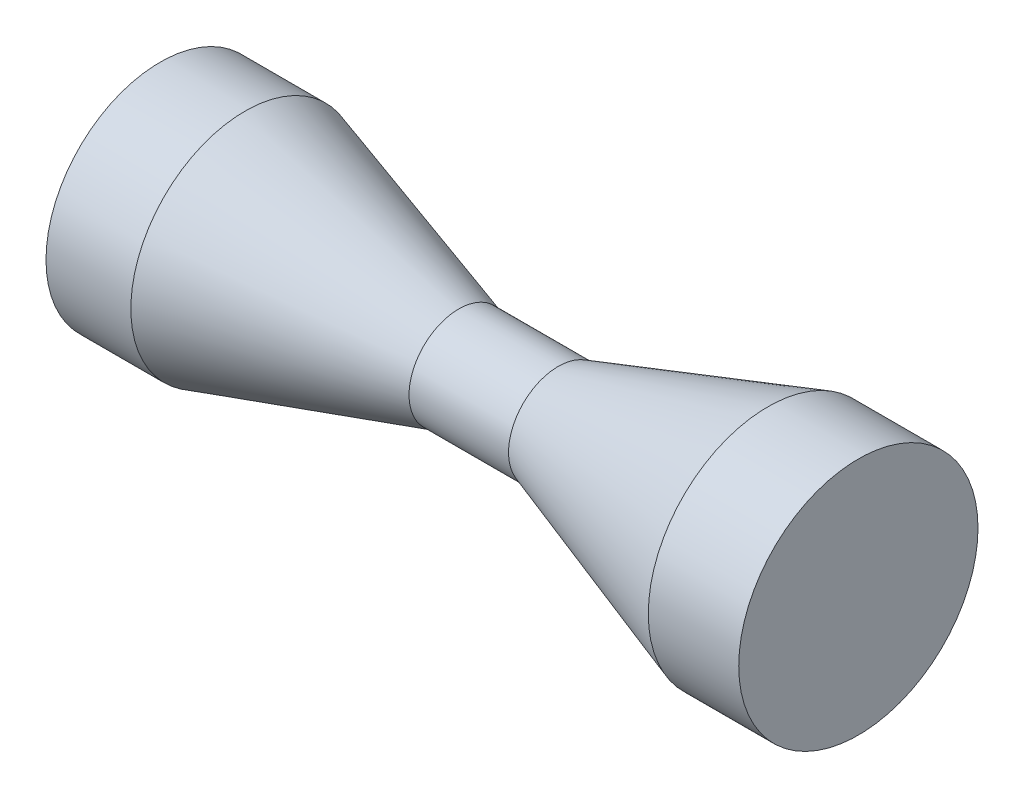
from build123d import *

# Parameters (mm, degrees)
SKETCH2_R           = 17.604244625
BOSS_EXTRUDE1_DEPTH = 2
SKETCH3_R           = 18.437955777
BOSS_EXTRUDE2_DEPTH = 2


with BuildPart() as part:
    # Sketch1 → Revolve-Thin2 (revolve)
    with BuildSketch(Plane.XY):
        Polygon((-49.689400151, 17.604244625), (-38.615762403, 17.604244625), (-5.678788589, 7.666364595), (9.653940601, 7.666364595), (41.968714147, 18.437955777), (53.905013296, 18.437955777), (53.905013296, 16.437955777), (42.293269467, 16.437955777), (9.978495921, 5.666364595), (-5.973941532, 5.666364595), (-38.910915347, 15.604244625), (-49.689400151, 15.604244625), align=None)
    revolve(axis=Axis((0, 0, 0), (-1, 0, 0)))

    # Sketch2 → Boss-Extrude1 (add)
    with BuildSketch(Plane.ZY.offset(49.689400151)):
        Circle(SKETCH2_R)
    extrude(amount=BOSS_EXTRUDE1_DEPTH)

    # Sketch3 → Boss-Extrude2 (add)
    with BuildSketch(Plane(origin=(53.905013296, 0, 0), x_dir=(0, 0, -1), z_dir=(1, 0, 0))):
        Circle(SKETCH3_R)
    extrude(amount=BOSS_EXTRUDE2_DEPTH)


solid = part.part
